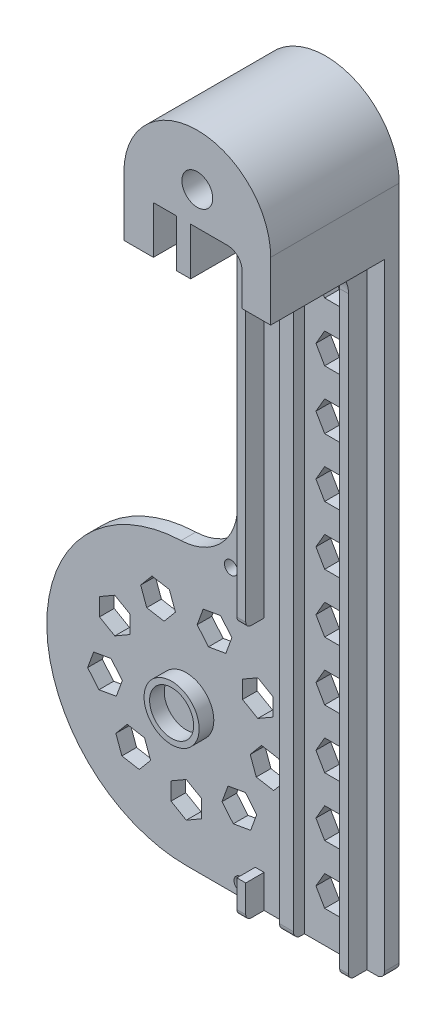
from build123d import *

# Parameters (mm, degrees)
BODYTOP_R                       = 19
BODY_TOP_DEPTH                  = 1
SKIZZE_LAMELLEN_W               = 1.2
SKIZZE_LAMELLEN_H               = 85
LAMMELLEN_DEPTH                 = 2.5
SKIZZE1_W                       = 1.9
SKIZZE1_H                       = 85
FUEHRUNG_DEPTH                  = 1.5
VERRUNDUNG6_R                   = 1
SPARUNG_W                       = 1.2
SPARUNG_H                       = 30
AUSSPARUNG_DEPTH                = 2.5
ANBAUPLATTE_DEPTH               = 1
ANBAUSTUTZEN_DEPTH              = 15.5
SKIZZEDRUCKERZAHNRAD_R          = 3.75
SKIZZEDRUCKERZAHNRAD_R_2        = 3
DRUCKER_ZAHNRAD_DEPTH           = 2
SKIZZEHALTERLOCH_R              = 2.1
HALTERLOCH_DEPTH                = 18.5
VERRUNDUNG24_R                  = 8
SKIZZEBOHRLOCH_R                = 0.9
BOHRLOCH_DEPTH                  = 10
SKIZZE6_W                       = 7.001894066
SKIZZE6_H                       = 6.469061082
SKIZZE6_W_2                     = 3.181141547
SCHNITT_LINEAR_AUSTRAGEN4_DEPTH = 15.5
VERRUNDUNG34_R                  = 1
SCHNITT_LINEAR_START            = -18.5000001
SCHNITT_LINEAR_AUSTRAGEN5_DEPTH = 19.5000002
LINEARES_MUSTER2_COUNT          = 11
LINEARES_MUSTER2_PITCH          = 8
SCHNITT_LINEAR_START_2          = -3.0000001
SCHNITT_LINEAR_AUSTRAGEN6_DEPTH = 19.5000002
KREISMUSTER1_COUNT              = 9
VERRUNDUNG35_R                  = 2
VERRUNDUNG36_R                  = 4
VERRUNDUNG37_R                  = 4
VERRUNDUNG38_R                  = 0.75


with BuildPart() as part:
    # BodyTop → body-top (new body, symmetric)
    with BuildSketch(Plane.XY):
        Circle(BODYTOP_R)
        with BuildLine():
            ThreePointArc((19, 0), (13.435028843, -13.435028843), (0, -19))
            Line((0, -19), (27, -19))
            Line((27, -19), (27, 66))
            Line((27, 66), (7, 66))
            Line((7, 66), (7, 19))
            Line((7, 19), (0, 19))
            ThreePointArc((0, 19), (13.435028843, 13.435028843), (19, 0))
        make_face()
    extrude(amount=BODY_TOP_DEPTH, both=True)

    # skizze_lamellen → Lammellen (add)
    with BuildSketch(Plane.XY.offset(1)):
        with Locations((24, 23.5)):
            Rectangle(SKIZZE_LAMELLEN_W, SKIZZE_LAMELLEN_H)
        with Locations((10, 23.5)):
            Rectangle(SKIZZE_LAMELLEN_W, SKIZZE_LAMELLEN_H)
    extrude(amount=LAMMELLEN_DEPTH)

    # Skizze1 → fuehrung (add)
    with BuildSketch(Plane.XY.offset(1)):
        with Locations((15.15, 23.5)):
            Rectangle(SKIZZE1_W, SKIZZE1_H)
    extrude(amount=FUEHRUNG_DEPTH)

    # Verrundung6
    verrundung6_edges = [part.edges().sort_by_distance(p)[0] for p in [
        (27, -19, 0),
    ]]
    fillet(verrundung6_edges, radius=VERRUNDUNG6_R)

    # sparung → Aussparung (cut)
    with BuildSketch(Plane.XY.offset(3.5)):
        with Locations((10, 0.5)):
            Rectangle(SPARUNG_W, SPARUNG_H)
    extrude(amount=-AUSSPARUNG_DEPTH, mode=Mode.SUBTRACT)

    # SkizzeAnbau → Anbauplatte (add, symmetric)
    with BuildSketch(Plane.XY):
        with BuildLine():
            Line((7, 74), (7, 66))
            Line((7, 66), (27, 66))
            Line((27, 66), (27, 74))
            ThreePointArc((27, 74), (17, 84), (7, 74))
        make_face()
    extrude(amount=ANBAUPLATTE_DEPTH, both=True)

    # SkizzeStutzen → anbaustutzen (add)
    with BuildSketch(Plane.XY.offset(1)):
        with BuildLine():
            Line((7, 66), (27, 66))
            Line((27, 66), (27, 74))
            ThreePointArc((27, 74), (17, 84), (7, 74))
            Line((7, 74), (7, 66))
        make_face()
    extrude(amount=ANBAUSTUTZEN_DEPTH)

    # Skizzedruckerzahnrad → drucker zahnrad (add)
    with BuildSketch(Plane.XY.offset(1)):
        Circle(SKIZZEDRUCKERZAHNRAD_R)
        Circle(SKIZZEDRUCKERZAHNRAD_R_2, mode=Mode.SUBTRACT)
    extrude(amount=DRUCKER_ZAHNRAD_DEPTH)

    # SkizzeHalterloch → halterloch (cut)
    with BuildSketch(Plane.XY.offset(16.5)):
        with Locations((17, 77)):
            Circle(SKIZZEHALTERLOCH_R)
    extrude(amount=-HALTERLOCH_DEPTH, mode=Mode.SUBTRACT)

    # Verrundung24
    verrundung24_edges = [part.edges().sort_by_distance(p)[0] for p in [
        (7, 19, 0),
    ]]
    fillet(verrundung24_edges, radius=VERRUNDUNG24_R)

    # Skizzebohrloch → bohrloch (cut)
    with BuildSketch(Plane.XY.offset(1)):
        with Locations((7.4, -17.5)):
            Circle(SKIZZEBOHRLOCH_R)
        with Locations((6.1, 19.2)):
            Circle(SKIZZEBOHRLOCH_R)
    extrude(amount=-BOHRLOCH_DEPTH, mode=Mode.SUBTRACT)

    # Skizze6 → Schnitt-Linear austragen4 (cut)
    with BuildSketch(Plane.XY.offset(16.5)):
        with Locations((19.600947033, 69.234530541)):
            Rectangle(SKIZZE6_W, SKIZZE6_H)
        with Locations((12.609429227, 69.234530541)):
            Rectangle(SKIZZE6_W_2, SKIZZE6_H)
    extrude(amount=-SCHNITT_LINEAR_AUSTRAGEN4_DEPTH, mode=Mode.SUBTRACT)

    # Verrundung34
    verrundung34_edges = [part.edges().sort_by_distance(p)[0] for p in [
        (15.15, -19, 2.5),
    ]]
    fillet(verrundung34_edges, radius=VERRUNDUNG34_R)

    # Skizze7 → Schnitt-Linear austragen5 (cut)
    with BuildSketch(Plane(origin=(0, 0, -1), x_dir=(-1, 0, 0), z_dir=(0, 0, -1)).offset(SCHNITT_LINEAR_START)):
        Polygon((-22.413127148, -12.56760803), (-21.225184268, -14.625185455), (-18.849298507, -14.625185455), (-17.661355626, -12.56760803), (-18.849298507, -10.510030604), (-21.225184268, -10.510030604), align=None)
    schnitt_linear_austragen5 = extrude(amount=SCHNITT_LINEAR_AUSTRAGEN5_DEPTH, mode=Mode.SUBTRACT)

    # Lineares Muster2: Schnitt-Linear austragen5 ×11
    with Locations(*[(0, i * LINEARES_MUSTER2_PITCH, 0) for i in range(1, LINEARES_MUSTER2_COUNT)]):
        add(schnitt_linear_austragen5, mode=Mode.SUBTRACT)

    # Skizze8 → Schnitt-Linear austragen6 (cut)
    with BuildSketch(Plane.XY.offset(1).offset(SCHNITT_LINEAR_START_2)):
        Polygon((0, -8.844754272), (-2.078547165, -10.044804037), (-2.078547165, -12.444903567), (0, -13.644953333), (2.078547165, -12.444903567), (2.078547165, -10.044804037), align=None)
    schnitt_linear_austragen6 = extrude(amount=SCHNITT_LINEAR_AUSTRAGEN6_DEPTH, mode=Mode.SUBTRACT)

    # Kreismuster1: Schnitt-Linear austragen6 ×9 about axis
    kreismuster1_axis = Axis((0, 0, 0), (0, 0, 1))
    for i in range(1, KREISMUSTER1_COUNT):
        add(schnitt_linear_austragen6.rotate(kreismuster1_axis, i * 360 / KREISMUSTER1_COUNT), mode=Mode.SUBTRACT)

    # Verrundung35
    verrundung35_edges = [part.edges().sort_by_distance(p)[0] for p in [
        (23.101894066, 72.469061082, 8.75),
    ]]
    fillet(verrundung35_edges, radius=VERRUNDUNG35_R)

    # Verrundung36
    verrundung36_edges = [part.edges().sort_by_distance(p)[0] for p in [
        (10, 66, 3.5),
    ]]
    fillet(verrundung36_edges, radius=VERRUNDUNG36_R)

    # Verrundung37
    verrundung37_edges = [part.edges().sort_by_distance(p)[0] for p in [
        (24, 66, 3.5),
    ]]
    fillet(verrundung37_edges, radius=VERRUNDUNG37_R)

    # Verrundung38
    verrundung38_edges = [part.edges().sort_by_distance(p)[0] for p in [
        (10, 15.5, 3.5),
        (10, -19, 3.5),
        (24, -19, 3.5),
    ]]
    fillet(verrundung38_edges, radius=VERRUNDUNG38_R)


solid = part.part
